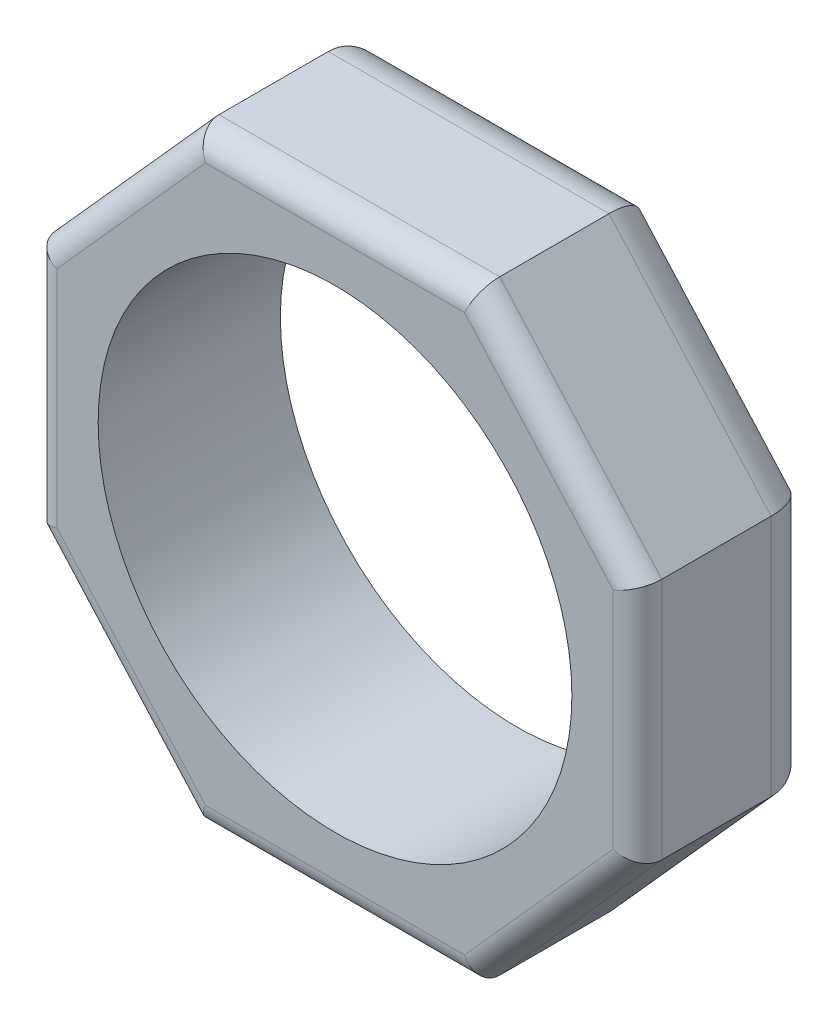
from build123d import *

# Parameters (mm, degrees)
BOSS_EXTRUDE1_DEPTH = 9.525
FILLET1_R           = 2.54
SKETCH2_R           = 12.3825
CUT_EXTRUDE1_DEPTH  = 10.525
FILLET2_R           = 1.27


with BuildPart() as part:
    # Sketch1 → Boss-Extrude1 (new body)
    with BuildSketch(Plane.XY):
        Polygon((-7.339781299, 15.8115), (7.339781299, 15.8115), (15.8115, 6.35), (15.8115, -6.35), (7.339781299, -15.8115), (-7.339781299, -15.8115), (-15.8115, -6.35), (-15.8115, 6.35), align=None)
    extrude(amount=BOSS_EXTRUDE1_DEPTH)

    # Fillet1
    fillet1_edges = [part.edges().sort_by_distance(p)[0] for p in [
        (15.8115, 0, 0),
        (11.575640649, -11.08075, 0),
        (0, -15.8115, 0),
        (-11.575640649, -11.08075, 0),
        (-15.8115, 0, 0),
        (-11.575640649, 11.08075, 0),
        (0, 15.8115, 0),
        (11.575640649, 11.08075, 0),
    ]]
    fillet(fillet1_edges, radius=FILLET1_R)

    # Sketch2 → Cut-Extrude1 (cut, through all)
    with BuildSketch(Plane(origin=(0, 0, 0), x_dir=(-1, 0, 0), z_dir=(0, 0, -1))):
        Circle(SKETCH2_R)
    extrude(amount=-CUT_EXTRUDE1_DEPTH, mode=Mode.SUBTRACT)

    # Fillet2
    fillet2_edges = [part.edges().sort_by_distance(p)[0] for p in [
        (11.575640649, -11.08075, 9.525),
        (15.8115, 0, 9.525),
        (11.575640649, 11.08075, 9.525),
        (0, 15.8115, 9.525),
        (-11.575640649, 11.08075, 9.525),
        (-15.8115, 0, 9.525),
        (-11.575640649, -11.08075, 9.525),
        (0, -15.8115, 9.525),
    ]]
    fillet(fillet2_edges, radius=FILLET2_R)


solid = part.part
